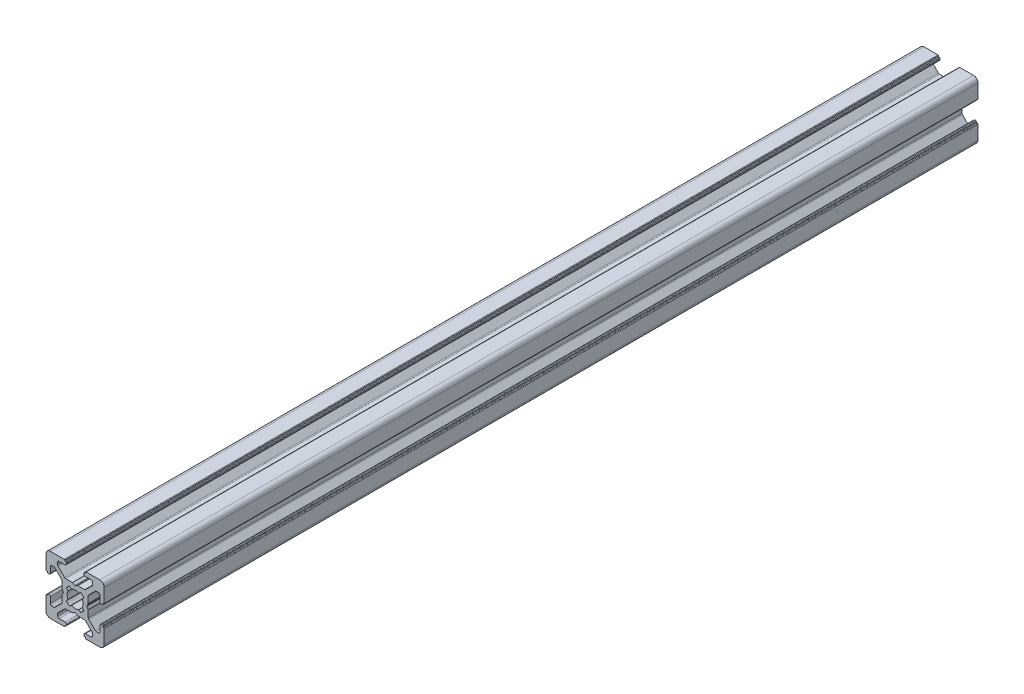
from build123d import *

# Parameters (mm, degrees)
EXTRUDE1_DEPTH = 300


with BuildPart() as part:
    # Sketch1 → Extrude1 (new body)
    with BuildSketch(Plane.XY):
        with BuildLine():
            Line((-3.5, 8.499999673), (-5.500000686, 8.499999673))
            ThreePointArc((-5.500000686, 8.499999673), (-5.853554077, 8.353553064), (-6.000000686, 7.999999673))
            Line((-6.000000686, 7.999999673), (-6.000000686, 7.267766626))
            ThreePointArc((-6.000000686, 7.267766626), (-5.961940448, 7.076424899), (-5.853554059, 6.914213219))
            Line((-5.853554059, 6.914213219), (-3.585787212, 4.646446592))
            ThreePointArc((-3.585787212, 4.646446592), (-3.423575544, 4.538060229), (-3.232233839, 4.5))
            Line((-3.232233839, 4.5), (-0.953590312, 4.5))
            ThreePointArc((-0.953590312, 4.5), (-0.901826505, 4.493185166), (-0.853590316, 4.473205083))
            Line((-0.853590316, 4.473205083), (-0.100000045, 4.038119562))
            ThreePointArc((-0.100000045, 4.038119562), (0, 4.011324632), (0.100000045, 4.038119562))
            Line((0.100000045, 4.038119562), (0.853590316, 4.473205083))
            ThreePointArc((0.853590316, 4.473205083), (0.901826505, 4.493185166), (0.953590312, 4.5))
            Line((0.953590312, 4.5), (3.232233839, 4.5))
            ThreePointArc((3.232233839, 4.5), (3.423575544, 4.538060229), (3.585787212, 4.646446592))
            Line((3.585787212, 4.646446592), (5.853554059, 6.914213219))
            ThreePointArc((5.853554059, 6.914213219), (5.961940448, 7.076424899), (6.000000686, 7.267766626))
            Line((6.000000686, 7.267766626), (6.000000686, 7.999999673))
            ThreePointArc((6.000000686, 7.999999673), (5.853554077, 8.353553064), (5.500000686, 8.499999673))
            Line((5.500000686, 8.499999673), (3.5, 8.499999673))
            ThreePointArc((3.5, 8.499999673), (3.146446609, 8.646446283), (3, 8.999999673))
            Line((3, 8.999999673), (3, 9.3))
            ThreePointArc((3, 9.3), (3.058578644, 9.441421356), (3.2, 9.5))
            Line((3.2, 9.5), (3.350000228, 9.5))
            ThreePointArc((3.350000228, 9.5), (3.491421584, 9.558578644), (3.550000228, 9.7))
            Line((3.550000228, 9.7), (3.550000228, 9.8))
            ThreePointArc((3.550000228, 9.8), (3.608578871, 9.941421356), (3.750000228, 10))
            Line((3.750000228, 10), (8.5, 10))
            ThreePointArc((8.5, 10), (9.560660172, 9.560660172), (10, 8.5))
            Line((10, 8.5), (10, 3.749999605))
            ThreePointArc((10, 3.749999605), (9.941421356, 3.608578248), (9.8, 3.549999605))
            Line((9.8, 3.549999605), (9.699999732, 3.549999605))
            ThreePointArc((9.699999732, 3.549999605), (9.558578376, 3.491420961), (9.499999732, 3.349999605))
            Line((9.499999732, 3.349999605), (9.499999732, 3.2))
            ThreePointArc((9.499999732, 3.2), (9.441421088, 3.058578644), (9.299999732, 3))
            Line((9.299999732, 3), (8.999999732, 3))
            ThreePointArc((8.999999732, 3), (8.646446341, 3.146446609), (8.499999732, 3.5))
            Line((8.499999732, 3.5), (8.499999732, 5.499999605))
            ThreePointArc((8.499999732, 5.499999605), (8.353553123, 5.853552995), (7.999999732, 5.999999605))
            Line((7.999999732, 5.999999605), (7.267766685, 5.999999605))
            ThreePointArc((7.267766685, 5.999999605), (7.076424969, 5.961939371), (6.914213294, 5.853552995))
            Line((6.914213294, 5.853552995), (4.646446398, 3.585786099))
            ThreePointArc((4.646446398, 3.585786099), (4.538060023, 3.423574425), (4.499999789, 3.232232708))
            Line((4.499999789, 3.232232708), (4.499999789, 0.953589302))
            ThreePointArc((4.499999789, 0.953589302), (4.493184953, 0.90182549), (4.473204867, 0.853589297))
            Line((4.473204867, 0.853589297), (4.038119841, 0.099999969))
            ThreePointArc((4.038119841, 0.099999969), (4.011324929, 0), (4.038119841, -0.099999969))
            Line((4.038119841, -0.099999969), (4.473204867, -0.853589297))
            ThreePointArc((4.473204867, -0.853589297), (4.493184953, -0.90182549), (4.499999789, -0.953589302))
            Line((4.499999789, -0.953589302), (4.499999789, -3.232232708))
            ThreePointArc((4.499999789, -3.232232708), (4.538060023, -3.423574425), (4.646446398, -3.585786099))
            Line((4.646446398, -3.585786099), (6.914213294, -5.853552995))
            ThreePointArc((6.914213294, -5.853552995), (7.076424969, -5.961939371), (7.267766685, -5.999999605))
            Line((7.267766685, -5.999999605), (7.999999732, -5.999999605))
            ThreePointArc((7.999999732, -5.999999605), (8.353553123, -5.853552995), (8.499999732, -5.499999605))
            Line((8.499999732, -5.499999605), (8.499999732, -3.5))
            ThreePointArc((8.499999732, -3.5), (8.646446341, -3.146446609), (8.999999732, -3))
            Line((8.999999732, -3), (9.299999732, -3))
            ThreePointArc((9.299999732, -3), (9.441421088, -3.058578644), (9.499999732, -3.2))
            Line((9.499999732, -3.2), (9.499999732, -3.349999605))
            ThreePointArc((9.499999732, -3.349999605), (9.558578376, -3.491420961), (9.699999732, -3.549999605))
            Line((9.699999732, -3.549999605), (9.8, -3.549999605))
            ThreePointArc((9.8, -3.549999605), (9.941421356, -3.608578248), (10, -3.749999605))
            Line((10, -3.749999605), (10, -8.5))
            ThreePointArc((10, -8.5), (9.560660172, -9.560660172), (8.5, -10))
            Line((8.5, -10), (3.750000228, -10))
            ThreePointArc((3.750000228, -10), (3.608578871, -9.941421356), (3.550000228, -9.8))
            Line((3.550000228, -9.8), (3.550000228, -9.7))
            ThreePointArc((3.550000228, -9.7), (3.491421584, -9.558578644), (3.350000228, -9.5))
            Line((3.350000228, -9.5), (3.2, -9.5))
            ThreePointArc((3.2, -9.5), (3.058578644, -9.441421356), (3, -9.3))
            Line((3, -9.3), (3, -8.999999673))
            ThreePointArc((3, -8.999999673), (3.146446609, -8.646446283), (3.5, -8.499999673))
            Line((3.5, -8.499999673), (5.500000686, -8.499999673))
            ThreePointArc((5.500000686, -8.499999673), (5.853554077, -8.353553064), (6.000000686, -7.999999673))
            Line((6.000000686, -7.999999673), (6.000000686, -7.267766626))
            ThreePointArc((6.000000686, -7.267766626), (5.961940448, -7.076424899), (5.853554059, -6.914213219))
            Line((5.853554059, -6.914213219), (3.585787212, -4.646446592))
            ThreePointArc((3.585787212, -4.646446592), (3.423575544, -4.538060229), (3.232233839, -4.5))
            Line((3.232233839, -4.5), (0.953590312, -4.5))
            ThreePointArc((0.953590312, -4.5), (0.901826505, -4.493185166), (0.853590316, -4.473205083))
            Line((0.853590316, -4.473205083), (0.100000045, -4.038119562))
            ThreePointArc((0.100000045, -4.038119562), (0, -4.011324632), (-0.100000045, -4.038119562))
            Line((-0.100000045, -4.038119562), (-0.853590316, -4.473205083))
            ThreePointArc((-0.853590316, -4.473205083), (-0.901826505, -4.493185166), (-0.953590312, -4.5))
            Line((-0.953590312, -4.5), (-3.232233839, -4.5))
            ThreePointArc((-3.232233839, -4.5), (-3.423575544, -4.538060229), (-3.585787212, -4.646446592))
            Line((-3.585787212, -4.646446592), (-5.853554059, -6.914213219))
            ThreePointArc((-5.853554059, -6.914213219), (-5.961940448, -7.076424899), (-6.000000686, -7.267766626))
            Line((-6.000000686, -7.267766626), (-6.000000686, -7.999999673))
            ThreePointArc((-6.000000686, -7.999999673), (-5.853554077, -8.353553064), (-5.500000686, -8.499999673))
            Line((-5.500000686, -8.499999673), (-3.5, -8.499999673))
            ThreePointArc((-3.5, -8.499999673), (-3.146446609, -8.646446283), (-3, -8.999999673))
            Line((-3, -8.999999673), (-3, -9.3))
            ThreePointArc((-3, -9.3), (-3.058578644, -9.441421356), (-3.2, -9.5))
            Line((-3.2, -9.5), (-3.350000228, -9.5))
            ThreePointArc((-3.350000228, -9.5), (-3.491421584, -9.558578644), (-3.550000228, -9.7))
            Line((-3.550000228, -9.7), (-3.550000228, -9.8))
            ThreePointArc((-3.550000228, -9.8), (-3.608578871, -9.941421356), (-3.750000228, -10))
            Line((-3.750000228, -10), (-8.5, -10))
            ThreePointArc((-8.5, -10), (-9.560660172, -9.560660172), (-10, -8.5))
            Line((-10, -8.5), (-10, -3.749999605))
            ThreePointArc((-10, -3.749999605), (-9.941421356, -3.608578248), (-9.8, -3.549999605))
            Line((-9.8, -3.549999605), (-9.699999732, -3.549999605))
            ThreePointArc((-9.699999732, -3.549999605), (-9.558578376, -3.491420961), (-9.499999732, -3.349999605))
            Line((-9.499999732, -3.349999605), (-9.499999732, -3.2))
            ThreePointArc((-9.499999732, -3.2), (-9.441421088, -3.058578644), (-9.299999732, -3))
            Line((-9.299999732, -3), (-8.999999732, -3))
            ThreePointArc((-8.999999732, -3), (-8.646446341, -3.146446609), (-8.499999732, -3.5))
            Line((-8.499999732, -3.5), (-8.499999732, -5.499999605))
            ThreePointArc((-8.499999732, -5.499999605), (-8.353553123, -5.853552995), (-7.999999732, -5.999999605))
            Line((-7.999999732, -5.999999605), (-7.267766685, -5.999999605))
            ThreePointArc((-7.267766685, -5.999999605), (-7.076424969, -5.961939371), (-6.914213294, -5.853552995))
            Line((-6.914213294, -5.853552995), (-4.646446398, -3.585786099))
            ThreePointArc((-4.646446398, -3.585786099), (-4.538060023, -3.423574425), (-4.499999789, -3.232232708))
            Line((-4.499999789, -3.232232708), (-4.499999789, -0.953589302))
            ThreePointArc((-4.499999789, -0.953589302), (-4.493184953, -0.90182549), (-4.473204867, -0.853589297))
            Line((-4.473204867, -0.853589297), (-4.038119841, -0.099999969))
            ThreePointArc((-4.038119841, -0.099999969), (-4.011324929, 0), (-4.038119841, 0.099999969))
            Line((-4.038119841, 0.099999969), (-4.473204867, 0.853589297))
            ThreePointArc((-4.473204867, 0.853589297), (-4.493184953, 0.90182549), (-4.499999789, 0.953589302))
            Line((-4.499999789, 0.953589302), (-4.499999789, 3.232232708))
            ThreePointArc((-4.499999789, 3.232232708), (-4.538060023, 3.423574425), (-4.646446398, 3.585786099))
            Line((-4.646446398, 3.585786099), (-6.914213294, 5.853552995))
            ThreePointArc((-6.914213294, 5.853552995), (-7.076424969, 5.961939371), (-7.267766685, 5.999999605))
            Line((-7.267766685, 5.999999605), (-7.999999732, 5.999999605))
            ThreePointArc((-7.999999732, 5.999999605), (-8.353553123, 5.853552995), (-8.499999732, 5.499999605))
            Line((-8.499999732, 5.499999605), (-8.499999732, 3.5))
            ThreePointArc((-8.499999732, 3.5), (-8.646446341, 3.146446609), (-8.999999732, 3))
            Line((-8.999999732, 3), (-9.299999732, 3))
            ThreePointArc((-9.299999732, 3), (-9.441421088, 3.058578644), (-9.499999732, 3.2))
            Line((-9.499999732, 3.2), (-9.499999732, 3.349999605))
            ThreePointArc((-9.499999732, 3.349999605), (-9.558578376, 3.491420961), (-9.699999732, 3.549999605))
            Line((-9.699999732, 3.549999605), (-9.8, 3.549999605))
            ThreePointArc((-9.8, 3.549999605), (-9.941421356, 3.608578248), (-10, 3.749999605))
            Line((-10, 3.749999605), (-10, 8.5))
            ThreePointArc((-10, 8.5), (-9.560660172, 9.560660172), (-8.5, 10))
            Line((-8.5, 10), (-3.750000228, 10))
            ThreePointArc((-3.750000228, 10), (-3.608578871, 9.941421356), (-3.550000228, 9.8))
            Line((-3.550000228, 9.8), (-3.550000228, 9.7))
            ThreePointArc((-3.550000228, 9.7), (-3.491421584, 9.558578644), (-3.350000228, 9.5))
            Line((-3.350000228, 9.5), (-3.2, 9.5))
            ThreePointArc((-3.2, 9.5), (-3.058578644, 9.441421356), (-3, 9.3))
            Line((-3, 9.3), (-3, 8.999999673))
            ThreePointArc((-3, 8.999999673), (-3.146446609, 8.646446283), (-3.5, 8.499999673))
        make_face()
        with BuildLine():
            Line((-1.258185436, 2.445295362), (-1.91389502, 2.989640962))
            ThreePointArc((-1.91389502, 2.989640962), (-2.511737261, 2.508410485), (-2.992174953, 1.909930962))
            Line((-2.992174953, 1.909930962), (-2.445295423, 1.258185317))
            ThreePointArc((-2.445295423, 1.258185317), (-2.75, 0), (-2.445295423, -1.258185317))
            Line((-2.445295423, -1.258185317), (-2.992174953, -1.909930962))
            ThreePointArc((-2.992174953, -1.909930962), (-2.511737261, -2.508410485), (-1.91389502, -2.989640962))
            Line((-1.91389502, -2.989640962), (-1.258185436, -2.445295362))
            ThreePointArc((-1.258185436, -2.445295362), (0, -2.75), (1.258185436, -2.445295362))
            Line((1.258185436, -2.445295362), (1.91389502, -2.989640962))
            ThreePointArc((1.91389502, -2.989640962), (2.511737261, -2.508410485), (2.992174953, -1.909930962))
            Line((2.992174953, -1.909930962), (2.445295423, -1.258185317))
            ThreePointArc((2.445295423, -1.258185317), (2.75, 0), (2.445295423, 1.258185317))
            Line((2.445295423, 1.258185317), (2.992174953, 1.909930962))
            ThreePointArc((2.992174953, 1.909930962), (2.511737261, 2.508410485), (1.91389502, 2.989640962))
            Line((1.91389502, 2.989640962), (1.258185436, 2.445295362))
            ThreePointArc((1.258185436, 2.445295362), (0, 2.75), (-1.258185436, 2.445295362))
        make_face(mode=Mode.SUBTRACT)
    extrude(amount=EXTRUDE1_DEPTH)


solid = part.part
